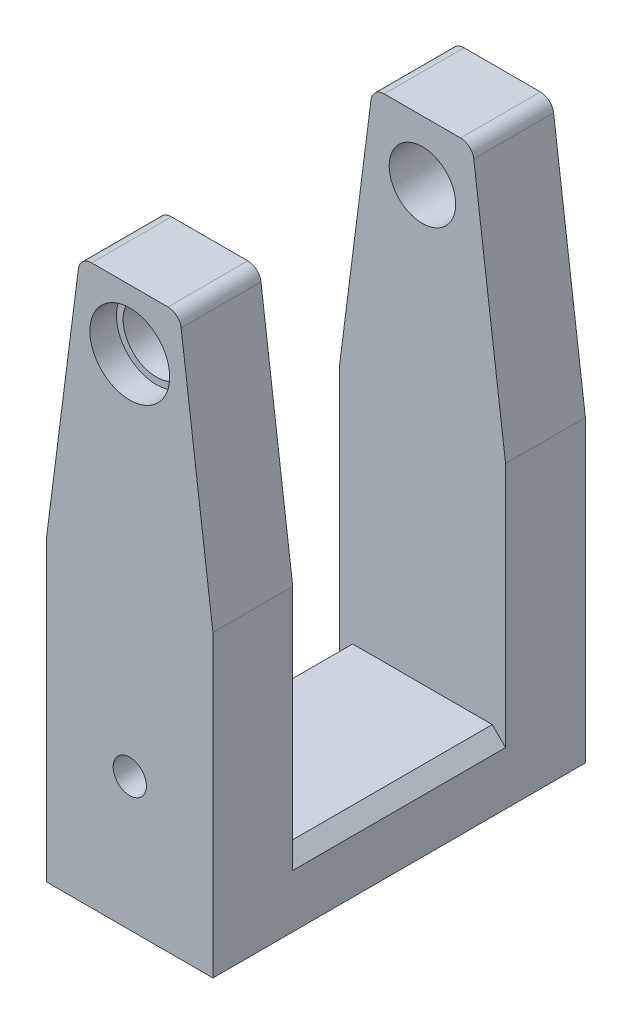
from build123d import *

# Parameters (mm, degrees)
BOSS_EXTRUDE2_DEPTH   = 28
SKETCH16_W            = 32
SKETCH16_H            = 74
CUT_EXTRUDE3_DEPTH    = 26
M6_TAPPED_HOLE1_D     = 5
M6_TAPPED_HOLE1_DEPTH = 27
M6_TAPPED_HOLE1_TIP   = 1.502151548
CHAMFER1_SIZE         = 2
FILLET1_R             = 2


with BuildPart() as part:
    # Sketch15 → Boss-Extrude2 (new body, symmetric)
    with BuildSketch(Plane.XY):
        Polygon((-12.5, 0), (12.5, 0), (12.5, 45), (7.5, 84), (-7.5, 84), (-12.5, 45), align=None)
    extrude(amount=BOSS_EXTRUDE2_DEPTH, both=True)

    # Sketch16 → Cut-Extrude3 (cut, through all)
    with BuildSketch(Plane(origin=(12.5, 0, 0), x_dir=(0, 0, -1), z_dir=(1, 0, 0))):
        with Locations((0, 47)):
            Rectangle(SKETCH16_W, SKETCH16_H)
    extrude(amount=-CUT_EXTRUDE3_DEPTH, mode=Mode.SUBTRACT)

    # Sketch18 → CBORE for M4 Hex Socket Head Cap Screw1 (revolve, cut)
    with BuildSketch(Plane(origin=(0, 75, 28), x_dir=(0, -1, 0), z_dir=(1, 0, 0))):
        Polygon((0, 0), (0, 23.004303095), (5, 20), (5, 4), (6, 4), (6, 0), align=None)
    cbore_for_m4_hex_socket_head_cap_screw1 = revolve(axis=Axis((0, 75, 34.35), (0, 0, -1)), mode=Mode.SUBTRACT)

    # Mirror1: CBORE for M4 Hex Socket Head Cap Screw1 across plane
    add(cbore_for_m4_hex_socket_head_cap_screw1.mirror(Plane.XY), mode=Mode.SUBTRACT)

    # M6 Tapped Hole1
    with Locations(Plane.XY.offset(28)):
        with Locations((0, 20)):
            Hole(M6_TAPPED_HOLE1_D / 2, depth=M6_TAPPED_HOLE1_DEPTH)
            with Locations((0, 0, -(M6_TAPPED_HOLE1_DEPTH + M6_TAPPED_HOLE1_TIP / 2))):  # 118° drill point
                Cone(0, M6_TAPPED_HOLE1_D / 2, M6_TAPPED_HOLE1_TIP, mode=Mode.SUBTRACT)

    # Chamfer1
    chamfer1_edges = [part.edges().sort_by_distance(p)[0] for p in [
        (12.5, 10, 0),
        (-12.5, 10, 0),
    ]]
    chamfer(chamfer1_edges, length=CHAMFER1_SIZE)

    # Fillet1
    fillet1_edges = [part.edges().sort_by_distance(p)[0] for p in [
        (-7.5, 84, 22),
        (7.5, 84, 22),
        (-7.5, 84, -22),
        (7.5, 84, -22),
    ]]
    fillet(fillet1_edges, radius=FILLET1_R)


solid = part.part
